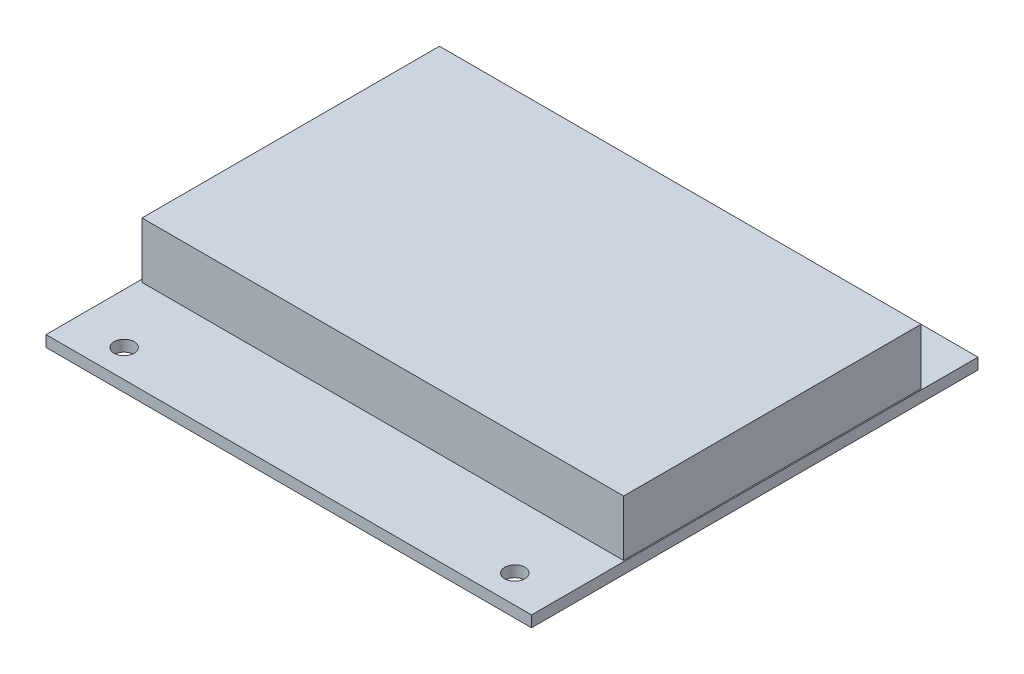
from build123d import *

# Parameters (mm, degrees)
SKETCH1_W              = 87
SKETCH1_H              = 80
PCB_DEPTH              = 2
SKETCH2_R              = 1.8
ATTACHMENT_HOLES_DEPTH = 3
LPATTERN1_COUNT        = 2
LPATTERN1_PITCH        = 70
LPATTERN1_COUNT_DIR2   = 2
LPATTERN1_PITCH_DIR2   = 70
SKETCH3_W              = 86.3
SKETCH3_H              = 53.3
IDUINO_DEPTH           = 10


with BuildPart() as part:
    # Sketch1 → PCB (new body)
    with BuildSketch(Plane(origin=(0, 0, 0), x_dir=(1, 0, 0), z_dir=(0, 1, 0))):
        with Locations((43.5, 40)):
            Rectangle(SKETCH1_W, SKETCH1_H)
    extrude(amount=PCB_DEPTH)

    # Sketch2 → Attachment Holes (cut, through all)
    with BuildSketch(Plane(origin=(0, 2, 0), x_dir=(1, 0, 0), z_dir=(0, 1, 0))):
        with Locations((9, 75)):
            Circle(SKETCH2_R)
    attachment_holes = extrude(amount=-ATTACHMENT_HOLES_DEPTH, mode=Mode.SUBTRACT)

    # LPattern1: Attachment Holes 2 × 2
    with Locations(*[(i * LPATTERN1_PITCH, 0, j * LPATTERN1_PITCH_DIR2) for i in range(LPATTERN1_COUNT) for j in range(LPATTERN1_COUNT_DIR2) if (i, j) != (0, 0)]):
        add(attachment_holes, mode=Mode.SUBTRACT)

    # Sketch3 → Iduino (add)
    with BuildSketch(Plane(origin=(0, 2, 0), x_dir=(1, 0, 0), z_dir=(0, 1, 0))):
        with Locations((43.65, 43.35)):
            Rectangle(SKETCH3_W, SKETCH3_H)
    extrude(amount=IDUINO_DEPTH)


solid = part.part
